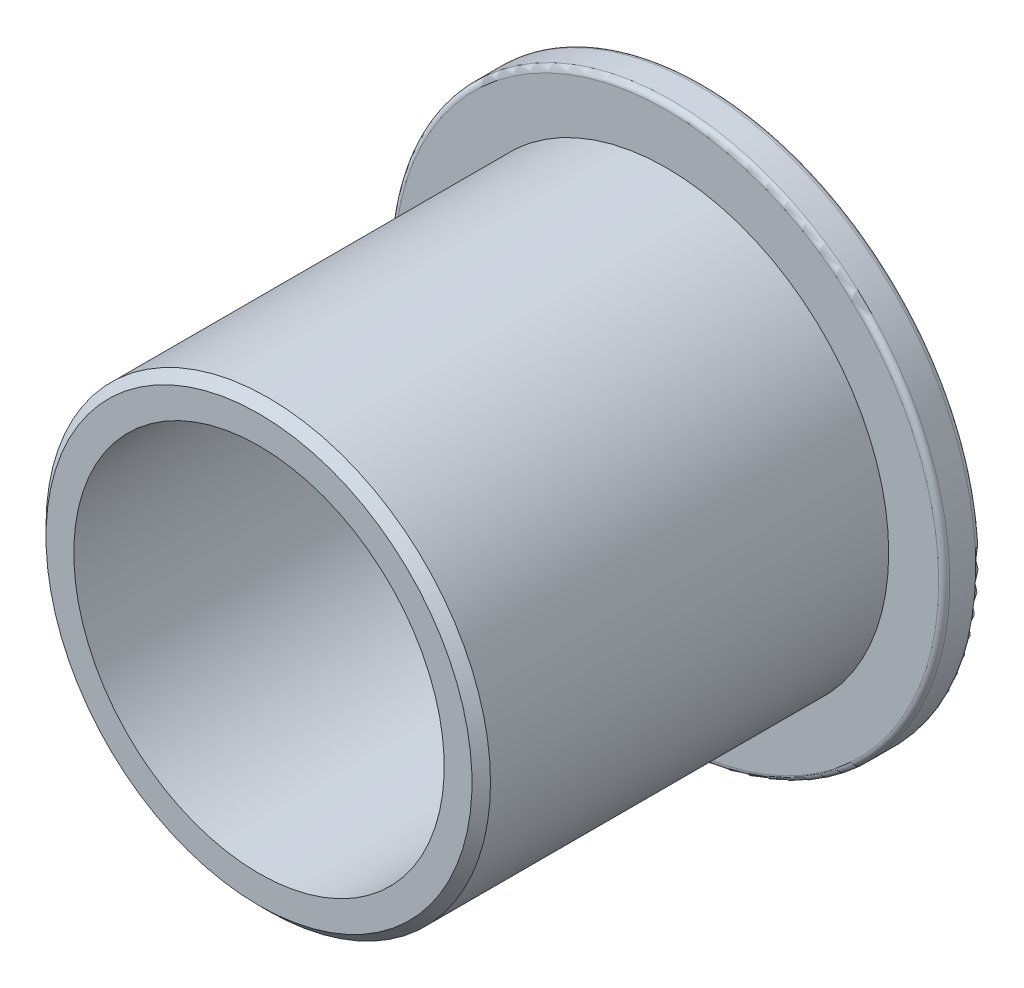
from build123d import *

# Parameters (mm, degrees)
CHAMFER1_SIZE = 0.396875
FILLET2_R     = 0.238125
CHAMFER2_SIZE = 0.79375


with BuildPart() as part:
    # Sketch3 → Revolve1 (revolve)
    with BuildSketch(Plane(origin=(0, 0, 0), x_dir=(0, 0, -1), z_dir=(1, 0, 0)), mode=Mode.PRIVATE) as revolve1_sk:
        Polygon((-9.525, 7.9375), (9.525, 7.9375), (9.525, 11.90625), (7.9375, 11.90625), (7.9375, 9.525), (-9.525, 9.525), align=None)
    revolve(revolve1_sk.sketch.rotate(Axis((0, 0, 9.525), (0, 0, -1)), 180), axis=Axis((0, 0, 9.525), (0, 0, -1)))

    # Chamfer1
    chamfer1_edges = [part.edges().sort_by_distance(p)[0] for p in [
        (0, 9.525, 9.525),
    ]]
    chamfer(chamfer1_edges, length=CHAMFER1_SIZE)

    # Fillet2
    fillet2_edges = [part.edges().sort_by_distance(p)[0] for p in [
        (0, 11.90625, -7.9375),
        (0, 11.90625, -9.525),
    ]]
    fillet(fillet2_edges, radius=FILLET2_R)

    # Chamfer2
    chamfer2_edges = [part.edges().sort_by_distance(p)[0] for p in [
        (0, 7.9375, -9.525),
    ]]
    chamfer(chamfer2_edges, length=CHAMFER2_SIZE)


solid = part.part
